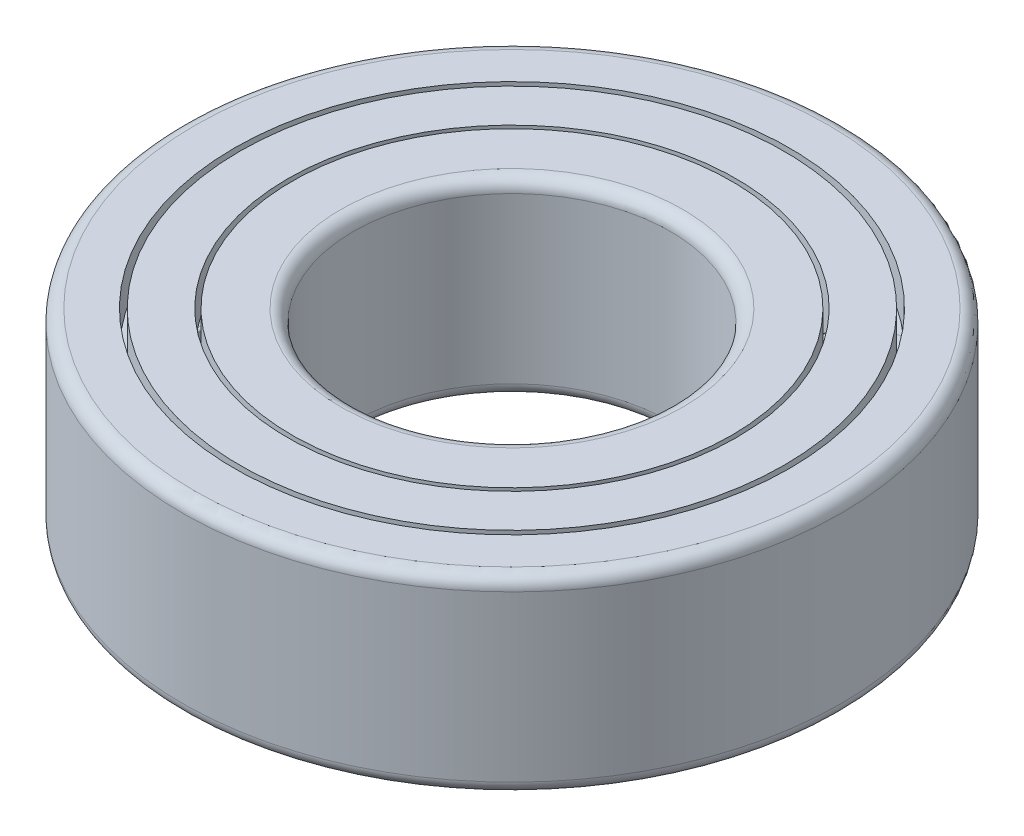
from build123d import *

# Parameters (mm, degrees)
SKETCH6_R            = 3.75
BOSS_EXTRUDE4_DEPTH  = 4.5
FILLET1_R            = 0.2
CIRPATTERN2_COUNT    = 13
SKETCH9_R            = 21.462
SKETCH9_R_2          = 17.697
BOSS_EXTRUDE7_DEPTH  = 15
SKETCH10_R           = 23.25
SKETCH10_R_2         = 19.5795
BOSS_EXTRUDE11_DEPTH = 9


with BuildPart() as part:
    # Sketch2 → Revolve3 (revolve)
    with BuildSketch(Plane.XY):
        with BuildLine():
            Line((15.1499995, -7.5), (15.75, -5.260767649))
            Line((15.75, -5.260767649), (15.75, 4.146163767))
            Line((15.75, 4.146163767), (15.573081883, 4.323081883))
            ThreePointArc((15.573081883, 4.323081883), (15.573081883, 4.676918117), (15.926918117, 4.676918117))
            Line((15.926918117, 4.676918117), (16.103836233, 4.5))
            Line((16.103836233, 4.5), (17.35, 4.5))
            Line((17.35, 4.5), (17.35, 7.5))
            Line((17.35, 7.5), (13.5, 7.5))
            ThreePointArc((13.5, 7.5), (12.792893219, 7.207106781), (12.5, 6.5))
            Line((12.5, 6.5), (12.5, -6.5))
            ThreePointArc((12.5, -6.5), (12.792893219, -7.207106781), (13.5, -7.5))
            Line((13.5, -7.5), (15.1499995, -7.5))
        make_face()
    revolve(axis=Axis((0, 0, 0), (0, 1, 0)))


with BuildPart() as body_2:
    # Sketch5 → Revolve4 (revolve)
    with BuildSketch(Plane.XY):
        with BuildLine():
            Line((21.9, 7.5), (21.9, 4.5))
            Line((21.9, 4.5), (22.896163767, 4.5))
            Line((22.896163767, 4.5), (23.073081883, 4.676918117))
            ThreePointArc((23.073081883, 4.676918117), (23.426918117, 4.676918117), (23.426918117, 4.323081883))
            Line((23.426918117, 4.323081883), (23.25, 4.146163767))
            Line((23.25, 4.146163767), (23.25, -4.146163767))
            Line((23.25, -4.146163767), (23.426918117, -4.323081883))
            ThreePointArc((23.426918117, -4.323081883), (23.426918117, -4.676918117), (23.073081883, -4.676918117))
            Line((23.073081883, -4.676918117), (22.896163767, -4.5))
            Line((22.896163767, -4.5), (21.9, -4.5))
            Line((21.9, -4.5), (21.9, -7.5))
            Line((21.9, -7.5), (25, -7.5))
            ThreePointArc((25, -7.5), (25.707106781, -7.207106781), (26, -6.5))
            Line((26, -6.5), (26, 6.5))
            ThreePointArc((26, 6.5), (25.707106781, 7.207106781), (25, 7.5))
            Line((25, 7.5), (21.9, 7.5))
        make_face()
    revolve(axis=Axis((0, 0, 0), (0, 1, 0)))


with BuildPart() as body_3:
    # Sketch6 → Boss-Extrude4 (new body, symmetric)
    with BuildSketch(Plane(origin=(0, 0, 0), x_dir=(1, 0, 0), z_dir=(0, 1, 0))):
        with Locations((-19.5, 0)):
            Circle(SKETCH6_R)
    extrude(amount=BOSS_EXTRUDE4_DEPTH, both=True)

    # Fillet1
    fillet1_edges = [body_3.edges().sort_by_distance(p)[0] for p in [
        (-23.25, -4.5, 0),
        (-23.25, 4.5, 0),
    ]]
    fillet(fillet1_edges, radius=FILLET1_R)


with BuildPart() as cirpattern2_1:
    # CirPattern2: pattern copy
    add(body_3.part.rotate(Axis((0, 0, 0), (0, 1, 0)), 1 * 360 / CIRPATTERN2_COUNT))


with BuildPart() as cirpattern2_2:
    # CirPattern2: pattern copy
    add(body_3.part.rotate(Axis((0, 0, 0), (0, 1, 0)), 2 * 360 / CIRPATTERN2_COUNT))


with BuildPart() as cirpattern2_3:
    # CirPattern2: pattern copy
    add(body_3.part.rotate(Axis((0, 0, 0), (0, 1, 0)), 3 * 360 / CIRPATTERN2_COUNT))


with BuildPart() as cirpattern2_4:
    # CirPattern2: pattern copy
    add(body_3.part.rotate(Axis((0, 0, 0), (0, 1, 0)), 4 * 360 / CIRPATTERN2_COUNT))


with BuildPart() as cirpattern2_5:
    # CirPattern2: pattern copy
    add(body_3.part.rotate(Axis((0, 0, 0), (0, 1, 0)), 5 * 360 / CIRPATTERN2_COUNT))


with BuildPart() as cirpattern2_6:
    # CirPattern2: pattern copy
    add(body_3.part.rotate(Axis((0, 0, 0), (0, 1, 0)), 6 * 360 / CIRPATTERN2_COUNT))


with BuildPart() as cirpattern2_7:
    # CirPattern2: pattern copy
    add(body_3.part.rotate(Axis((0, 0, 0), (0, 1, 0)), 7 * 360 / CIRPATTERN2_COUNT))


with BuildPart() as cirpattern2_8:
    # CirPattern2: pattern copy
    add(body_3.part.rotate(Axis((0, 0, 0), (0, 1, 0)), 8 * 360 / CIRPATTERN2_COUNT))


with BuildPart() as cirpattern2_9:
    # CirPattern2: pattern copy
    add(body_3.part.rotate(Axis((0, 0, 0), (0, 1, 0)), 9 * 360 / CIRPATTERN2_COUNT))


with BuildPart() as cirpattern2_10:
    # CirPattern2: pattern copy
    add(body_3.part.rotate(Axis((0, 0, 0), (0, 1, 0)), 10 * 360 / CIRPATTERN2_COUNT))


with BuildPart() as cirpattern2_11:
    # CirPattern2: pattern copy
    add(body_3.part.rotate(Axis((0, 0, 0), (0, 1, 0)), 11 * 360 / CIRPATTERN2_COUNT))


with BuildPart() as cirpattern2_12:
    # CirPattern2: pattern copy
    add(body_3.part.rotate(Axis((0, 0, 0), (0, 1, 0)), 12 * 360 / CIRPATTERN2_COUNT))


with BuildPart() as body_16:
    # Sketch9 → Boss-Extrude7 (new body)
    with BuildSketch(Plane.XZ.offset(7.5)):
        Circle(SKETCH9_R)
        Circle(SKETCH9_R_2, mode=Mode.SUBTRACT)
    extrude(amount=-BOSS_EXTRUDE7_DEPTH)


with BuildPart() as body_17:
    # Sketch10 → Boss-Extrude11 (new body)
    with BuildSketch(Plane.XZ.offset(4.5)):
        Circle(SKETCH10_R)
        Circle(SKETCH10_R_2, mode=Mode.SUBTRACT)
    extrude(amount=-BOSS_EXTRUDE11_DEPTH)


solid = Compound([part.part, body_2.part, body_3.part, cirpattern2_1.part, cirpattern2_2.part, cirpattern2_3.part, cirpattern2_4.part, cirpattern2_5.part, cirpattern2_6.part, cirpattern2_7.part, cirpattern2_8.part, cirpattern2_9.part, cirpattern2_10.part, cirpattern2_11.part, cirpattern2_12.part, body_16.part, body_17.part])
